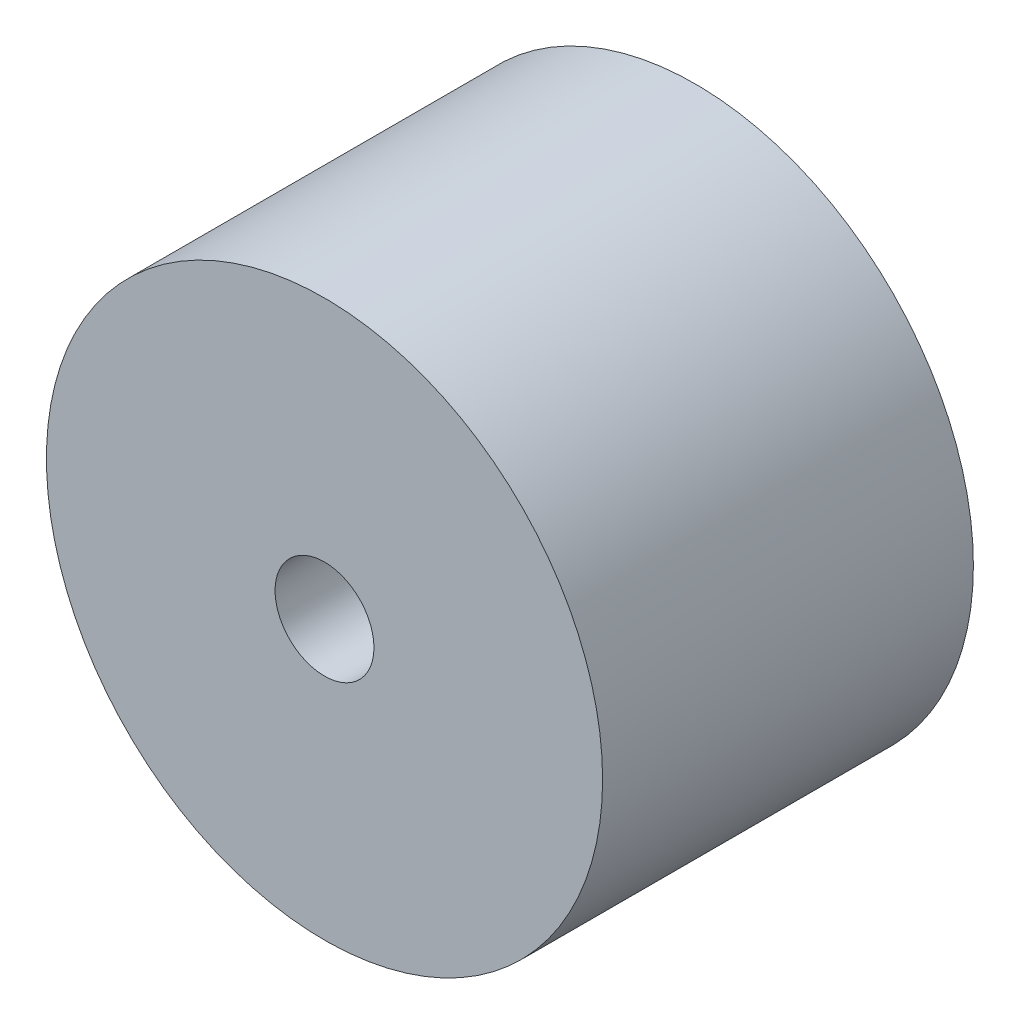
from build123d import *

# Parameters (mm, degrees)
SKETCH1_R           = 2.25
SKETCH1_R_2         = 0.4
BOSS_EXTRUDE1_DEPTH = 3


with BuildPart() as part:
    # Sketch1 → Boss-Extrude1 (new body)
    with BuildSketch(Plane.XY):
        Circle(SKETCH1_R)
        Circle(SKETCH1_R_2, mode=Mode.SUBTRACT)
    extrude(amount=BOSS_EXTRUDE1_DEPTH)


solid = part.part
